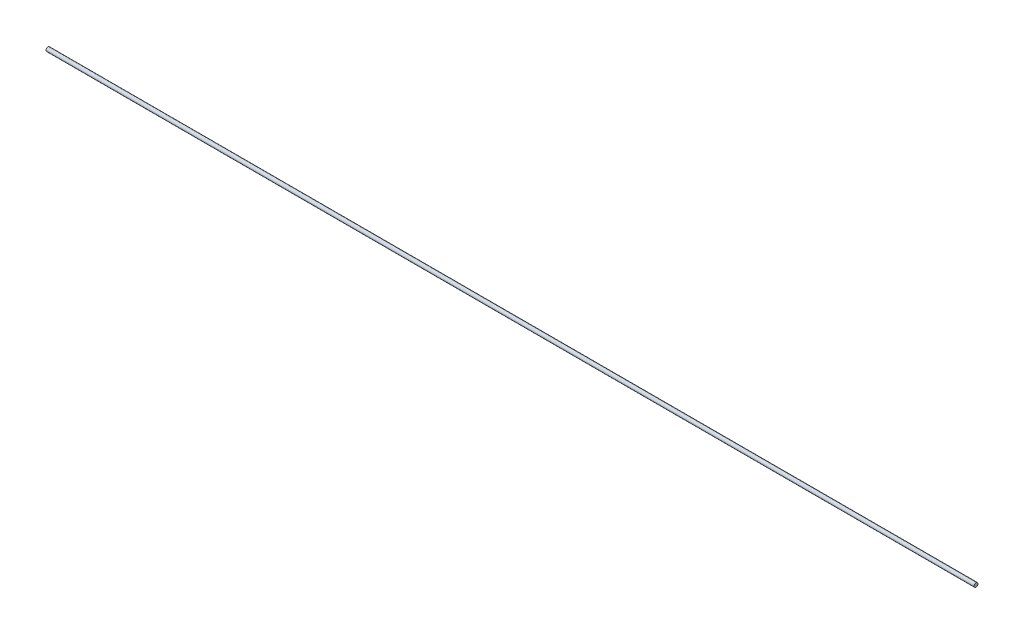
from build123d import *

# Parameters (mm, degrees)
SKETCH1_R           = 0.635
BOSS_EXTRUDE1_DEPTH = 300


with BuildPart() as part:
    # Sketch1 → Boss-Extrude1 (new body)
    with BuildSketch(Plane(origin=(0, 0, 0), x_dir=(0, 0, -1), z_dir=(1, 0, 0))):
        Circle(SKETCH1_R)
    extrude(amount=BOSS_EXTRUDE1_DEPTH)


solid = part.part
